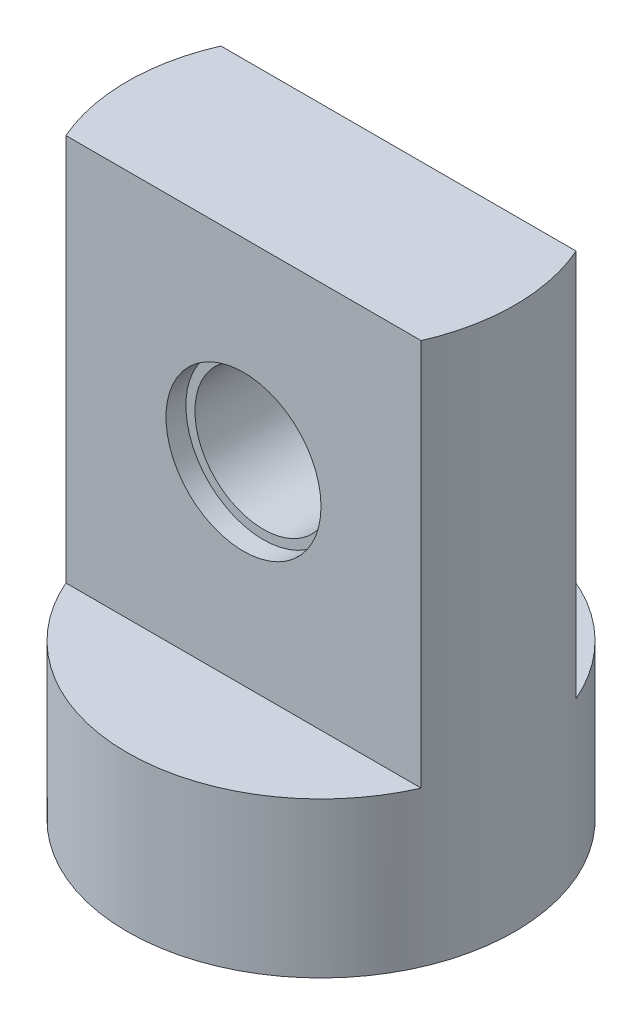
from build123d import *

# Parameters (mm, degrees)
SKETCH1_R           = 7.5
BOSS_EXTRUDE6_DEPTH = 6
BOSS_EXTRUDE7_DEPTH = 21
SKETCH4_R           = 2.65
CUT_EXTRUDE7_DEPTH  = 6
SKETCH7_R           = 3
CUT_EXTRUDE8_DEPTH  = 0.77
SKETCH8_R           = 2.3
CUT_EXTRUDE9_DEPTH  = 6


with BuildPart() as part:
    # Sketch1 → Boss-Extrude6 (new body)
    with BuildSketch(Plane(origin=(0, 0, 0), x_dir=(1, 0, 0), z_dir=(0, 1, 0))):
        Circle(SKETCH1_R)
    extrude(amount=BOSS_EXTRUDE6_DEPTH)

    # Sketch1_9 → Boss-Extrude7 (add)
    with BuildSketch(Plane(origin=(0, 0, 0), x_dir=(1, 0, 0), z_dir=(0, 1, 0))):
        with BuildLine():
            ThreePointArc((7.5, 0), (7.341797347, 1.532322328), (6.873863542, 3))
            Line((6.873863542, 3), (-6.873863542, 3))
            ThreePointArc((-6.873863542, 3), (-7.5, 0), (-6.873863542, -3))
            Line((-6.873863542, -3), (6.873863542, -3))
            ThreePointArc((6.873863542, -3), (7.341797347, -1.532322328), (7.5, 0))
        make_face()
    extrude(amount=BOSS_EXTRUDE7_DEPTH)

    # Sketch4 → Cut-Extrude7 (cut)
    with BuildSketch(Plane.XY.offset(3)):
        with Locations((0, 13.5)):
            Circle(SKETCH4_R)
    extrude(amount=-CUT_EXTRUDE7_DEPTH, mode=Mode.SUBTRACT)

    # Sketch7 → Cut-Extrude8 (cut)
    with BuildSketch(Plane.XY.offset(3)):
        with Locations((0, 13.5)):
            Circle(SKETCH7_R)
    extrude(amount=-CUT_EXTRUDE8_DEPTH, mode=Mode.SUBTRACT)

    # Sketch8 → Cut-Extrude9 (cut)
    with BuildSketch(Plane.XZ):
        Circle(SKETCH8_R)
    extrude(amount=-CUT_EXTRUDE9_DEPTH, mode=Mode.SUBTRACT)


solid = part.part
